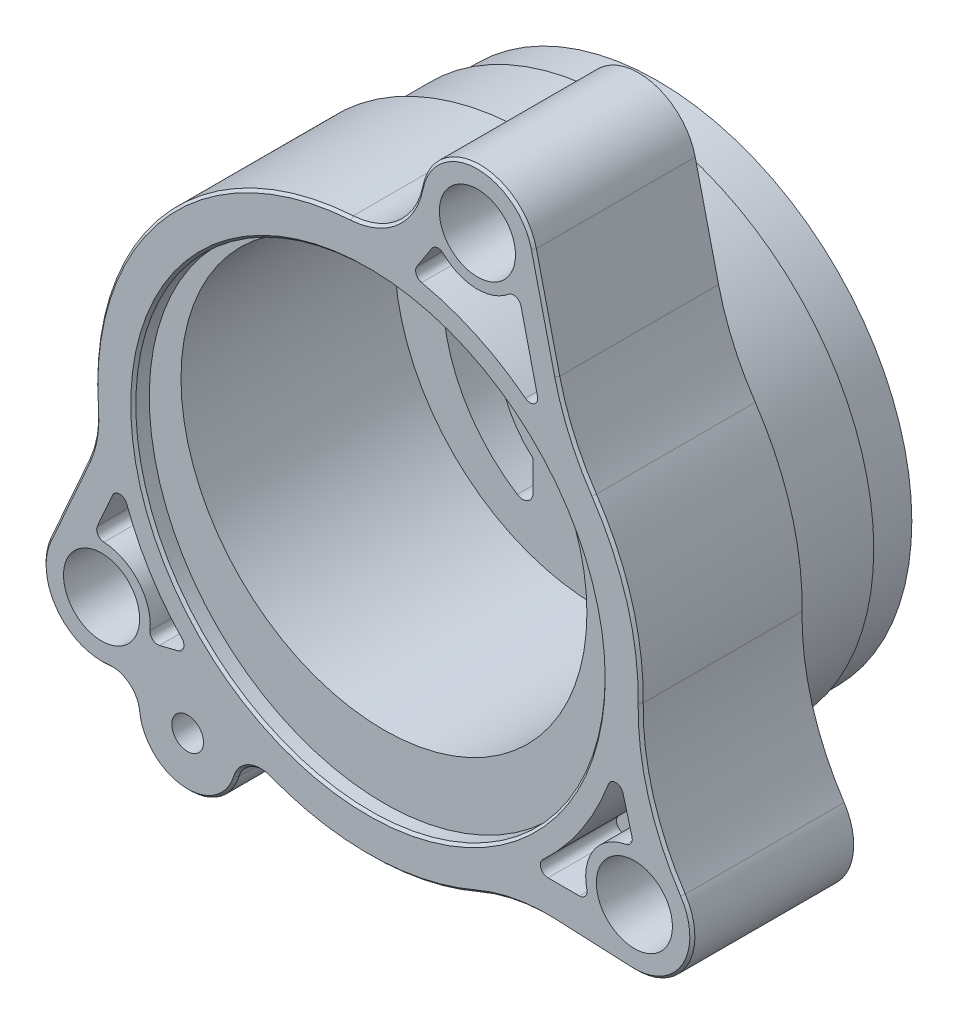
from build123d import *

# Parameters (mm, degrees)
BASE_DEPTH            = 16.1544
SKETCH2_R             = 25.9715
BOSS_I_DEPTH          = 8.509
SKETCH3_R             = 25.4635
BOSS_II_DEPTH         = 4.318
SKETCH4_R             = 23.495
TOP_SEAL_CUT_DEPTH    = 1.6002
SKETCH5_R             = 20.32
ECCENTRIC_DEPTH       = 21.3868
SKETCH6_R             = 23.9395
BOTTOM_SEAL_CUT_DEPTH = 1.27
INTAKE_PORT_DEPTH     = 29.9814
EXHAUST_PORT_DEPTH    = 29.9814
POCKET_1_DEPTH        = 2.794
POCKET_2_DEPTH        = 2.794
POCKET_3_DEPTH        = 2.794
SKETCH12_R            = 6.1595
SHAFT_BOSS_DEPTH      = 2.794
SKETCH13_R            = 4.8895
SHAFT_RACE_DEPTH      = 31.5054
FILLET1_R             = 0.127
SKETCH14_R            = 3.81
MOUNTING_HOLES_DEPTH  = 31.5054001
MOUNTING_HOLES_TAPER  = 3
CHAMFER1_SIZE         = 0.254
SKETCH15_R            = 1.5875
SCREW_HOLE_DEPTH      = 31.5054001
SKETCH16_R            = 3.302
SCREW_C_BORE_DEPTH    = 13.462
CASTING_CUTS_DEPTH    = 7.62


with BuildPart() as part:
    # Sketch1 → Base (new body)
    with BuildSketch(Plane.XY):
        with BuildLine():
            Line((16.604256141, 33.560634381), (18.943472312, 23.673588932))
            ThreePointArc((18.943472312, 23.673588932), (20.401103388, 19.31706117), (22.619598737, 15.294338102))
            ThreePointArc((22.619598737, 15.294338102), (26.177171365, 7.766513011), (27.300719551, -0.483463539))
            ThreePointArc((27.300719551, -0.483463539), (28.309281475, -8.033336288), (31.510952034, -14.944709618))
            ThreePointArc((31.510952034, -14.944709618), (31.716980405, -21.01221602), (26.400801283, -23.943993837))
            Line((26.400801283, -23.943993837), (18.789002246, -23.590560073))
            ThreePointArc((18.789002246, -23.590560073), (14.751162948, -23.864172006), (10.879801534, -25.043820467))
            ThreePointArc((10.879801534, -25.043820467), (0.563483635, -27.299185175), (-9.837113925, -25.471439194))
            ThreePointArc((-9.837113925, -25.471439194), (-11.86980955, -25.559968532), (-13.185383912, -27.112048762))
            ThreePointArc((-13.185383912, -27.112048762), (-18.53278197, -30.71157068), (-23.105685308, -26.168468316))
            ThreePointArc((-23.105685308, -26.168468316), (-24.05058816, -24.438373185), (-25.948431352, -23.905211124))
            ThreePointArc((-25.948431352, -23.905211124), (-31.329446418, -21.606804698), (-31.974558392, -15.791151184))
            Line((-31.974558392, -15.791151184), (-28.068905544, -6.994505511))
            ThreePointArc((-28.068905544, -6.994505511), (-27.342210837, -4.596155707), (-27.224673499, -2.092887453))
            ThreePointArc((-27.224673499, -2.092887453), (-20.610396453, 17.910180989), (-1.725707135, 27.250412105))
            ThreePointArc((-1.725707135, 27.250412105), (2.807988712, 29.118342831), (5.264931729, 33.361807717))
            ThreePointArc((5.264931729, 33.361807717), (10.854529977, 38.027365143), (16.604256141, 33.560634381))
        make_face()
    extrude(amount=BASE_DEPTH)

    # Sketch2 → Boss I (add)
    with BuildSketch(Plane(origin=(0, 0, 0), x_dir=(-1, 0, 0), z_dir=(0, 0, -1))):
        Circle(SKETCH2_R)
    extrude(amount=BOSS_I_DEPTH)

    # Sketch3 → Boss II (add)
    with BuildSketch(Plane(origin=(0, 0, -8.509), x_dir=(-1, 0, 0), z_dir=(0, 0, -1))):
        Circle(SKETCH3_R)
    extrude(amount=BOSS_II_DEPTH)

    # Sketch4 → Top Seal Cut (cut)
    with BuildSketch(Plane.XY.offset(16.1544)):
        Circle(SKETCH4_R)
    extrude(amount=-TOP_SEAL_CUT_DEPTH, mode=Mode.SUBTRACT)

    # Sketch5 → Eccentric (cut)
    with BuildSketch(Plane.XY.offset(14.5542)):
        with Locations((0, 3.175)):
            Circle(SKETCH5_R)
    extrude(amount=-ECCENTRIC_DEPTH, mode=Mode.SUBTRACT)

    # Sketch6 → Bottom Seal Cut (cut)
    with BuildSketch(Plane(origin=(0, 0, -12.827), x_dir=(-1, 0, 0), z_dir=(0, 0, -1))):
        Circle(SKETCH6_R)
        with BuildLine():
            Line((-1.27, 19.840574746), (-1.27, 10.506515883))
            ThreePointArc((-1.27, 10.506515883), (-1.730215265, 9.04840222), (-2.944090909, 8.118671364))
            ThreePointArc((-2.944090909, 8.118671364), (-8.636, 0), (-2.944090909, -8.118671364))
            ThreePointArc((-2.944090909, -8.118671364), (-1.730215265, -9.04840222), (-1.27, -10.506515883))
            Line((-1.27, -10.506515883), (-1.27, -19.840574746))
            ThreePointArc((-1.27, -19.840574746), (-1.70092691, -20.793914323), (-2.701269841, -21.100293777))
            ThreePointArc((-2.701269841, -21.100293777), (-21.2725, 0), (-2.701269841, 21.100293777))
            ThreePointArc((-2.701269841, 21.100293777), (-1.70092691, 20.793914323), (-1.27, 19.840574746))
        make_face(mode=Mode.SUBTRACT)
        with BuildLine():
            Line((1.27, 19.840574746), (1.27, 10.506515883))
            ThreePointArc((1.27, 10.506515883), (1.730215265, 9.04840222), (2.944090909, 8.118671364))
            ThreePointArc((2.944090909, 8.118671364), (8.636, 0), (2.944090909, -8.118671364))
            ThreePointArc((2.944090909, -8.118671364), (1.730215265, -9.04840222), (1.27, -10.506515883))
            Line((1.27, -10.506515883), (1.27, -19.840574746))
            ThreePointArc((1.27, -19.840574746), (1.70092691, -20.793914323), (2.701269841, -21.100293777))
            ThreePointArc((2.701269841, -21.100293777), (21.2725, 0), (2.701269841, 21.100293777))
            ThreePointArc((2.701269841, 21.100293777), (1.70092691, 20.793914323), (1.27, 19.840574746))
        make_face(mode=Mode.SUBTRACT)
    extrude(amount=-BOTTOM_SEAL_CUT_DEPTH, mode=Mode.SUBTRACT)

    # Sketch7 → Intake Port (cut, through all)
    with BuildSketch(Plane(origin=(0, 0, -12.827), x_dir=(-1, 0, 0), z_dir=(0, 0, -1))):
        with BuildLine():
            Line((6.477, 7.495152233), (6.477, 14.394282993))
            ThreePointArc((6.477, 14.394282993), (7.154191662, 15.517438492), (8.463579959, 15.44281204))
            ThreePointArc((8.463579959, 15.44281204), (15.47894101, 1.89335056), (8.039508682, -11.42798735))
            ThreePointArc((8.039508682, -11.42798735), (7.004633755, -11.462420973), (6.477, -10.571492014))
            Line((6.477, -10.571492014), (6.477, -7.495152233))
            ThreePointArc((6.477, -7.495152233), (9.906, 0), (6.477, 7.495152233))
        make_face()
    extrude(amount=-INTAKE_PORT_DEPTH, mode=Mode.SUBTRACT)

    # Sketch8 → Exhaust Port (cut, through all)
    with BuildSketch(Plane(origin=(0, 0, -12.827), x_dir=(-1, 0, 0), z_dir=(0, 0, -1))):
        with BuildLine():
            Line((-9.525, 2.720884231), (-9.525, 9.070884231))
            ThreePointArc((-9.525, 9.070884231), (-11.257750781, 11.254497488), (-13.777980834, 10.063265939))
            ThreePointArc((-13.777980834, 10.063265939), (-14.371790492, -2.970554124), (-5.192506336, -12.242760859))
            ThreePointArc((-5.192506336, -12.242760859), (-4.010815754, -12.112747852), (-3.4544, -11.062177758))
            Line((-3.4544, -11.062177758), (-3.4544, -9.284177758))
            ThreePointArc((-3.4544, -9.284177758), (-8.84005568, -4.47015118), (-9.525, 2.720884231))
        make_face()
    extrude(amount=-EXHAUST_PORT_DEPTH, mode=Mode.SUBTRACT)

    # Sketch9 → Pocket 1 (cut)
    with BuildSketch(Plane(origin=(0, 0, -12.827), x_dir=(-1, 0, 0), z_dir=(0, 0, -1))):
        with BuildLine():
            Line((3.1496, -11.299886076), (3.1496, -18.514300269))
            ThreePointArc((3.1496, -18.514300269), (3.431694665, -19.106191196), (4.069114094, -19.259842561))
            ThreePointArc((4.069114094, -19.259842561), (12.540368113, -15.173608423), (18.148870298, -7.623498667))
            ThreePointArc((18.148870298, -7.623498667), (18.080964228, -6.906628151), (17.446333383, -6.566395493))
            Line((17.446333383, -6.566395493), (15.786183774, -6.566395493))
            ThreePointArc((15.786183774, -6.566395493), (15.405217137, -6.668464873), (15.126310944, -6.947328768))
            ThreePointArc((15.126310944, -6.947328768), (12.518403705, -10.424638298), (9.159851479, -13.183802789))
            ThreePointArc((9.159851479, -13.183802789), (6.275256454, -13.420994092), (4.453004865, -11.172317298))
            ThreePointArc((4.453004865, -11.172317298), (3.74345607, -10.645069683), (3.1496, -11.299886076))
        make_face()
    extrude(amount=-POCKET_1_DEPTH, mode=Mode.SUBTRACT)

    # Sketch10 → Pocket 2 (cut)
    with BuildSketch(Plane(origin=(0, 0, -12.827), x_dir=(-1, 0, 0), z_dir=(0, 0, -1))):
        with BuildLine():
            Line((-3.1496, -16.375080355), (-3.1496, -18.514300269))
            ThreePointArc((-3.1496, -18.514300269), (-3.431694665, -19.106191196), (-4.069114094, -19.259842561))
            ThreePointArc((-4.069114094, -19.259842561), (-13.894614146, -13.944135783), (-19.245243831, -4.137609804))
            ThreePointArc((-19.245243831, -4.137609804), (-19.093010331, -3.498592586), (-18.50026665, -3.215444263))
            Line((-18.50026665, -3.215444263), (-17.792292075, -3.215444263))
            ThreePointArc((-17.792292075, -3.215444263), (-17.356402624, -3.352428754), (-17.077232582, -3.714130913))
            ThreePointArc((-17.077232582, -3.714130913), (-11.890715347, -11.339293456), (-3.730413278, -15.634934848))
            ThreePointArc((-3.730413278, -15.634934848), (-3.312138457, -15.904665794), (-3.1496, -16.375080355))
        make_face()
    extrude(amount=-POCKET_2_DEPTH, mode=Mode.SUBTRACT)

    # Sketch11 → Pocket 3 (cut)
    with BuildSketch(Plane(origin=(0, 0, -12.827), x_dir=(-1, 0, 0), z_dir=(0, 0, -1))):
        with BuildLine():
            Line((-3.1496, 17.890779888), (-3.1496, 9.712901548))
            ThreePointArc((-3.1496, 9.712901548), (-4.45441743, 9.187959621), (-5.674722083, 8.488696361))
            ThreePointArc((-5.674722083, 8.488696361), (-6.4542935, 8.448498977), (-6.860177613, 9.115286432))
            ThreePointArc((-6.860177613, 9.115286432), (-8.069580004, 12.29712311), (-11.058112281, 13.926667101))
            ThreePointArc((-11.058112281, 13.926667101), (-11.686704891, 14.493715403), (-11.403528613, 15.291514652))
            ThreePointArc((-11.403528613, 15.291514652), (-7.917467255, 17.354670767), (-4.074357282, 18.63519514))
            ThreePointArc((-4.074357282, 18.63519514), (-3.433780499, 18.484355936), (-3.1496, 17.890779888))
        make_face()
    extrude(amount=-POCKET_3_DEPTH, mode=Mode.SUBTRACT)

    # Sketch12 → Shaft Boss (add)
    with BuildSketch(Plane(origin=(0, 0, -11.557), x_dir=(-1, 0, 0), z_dir=(0, 0, -1))):
        Circle(SKETCH12_R)
    extrude(amount=SHAFT_BOSS_DEPTH)

    # Sketch13 → Shaft Race (cut, through all)
    with BuildSketch(Plane(origin=(0, 0, -14.351), x_dir=(-1, 0, 0), z_dir=(0, 0, -1))):
        Circle(SKETCH13_R)
    extrude(amount=-SHAFT_RACE_DEPTH, mode=Mode.SUBTRACT)

    # Fillet1
    fillet1_edges = [part.edges().sort_by_distance(p)[0] for p in [
        (-9.906, 0, -12.827),
        (-6.477, 10.944717613, -12.827),
        (-15.47894101, 1.89335056, -12.827),
        (-7.004633755, -11.462420973, -12.827),
        (-6.477, -9.033322123, -12.827),
        (-7.154191662, 15.517438492, -12.827),
        (8.84005568, -4.47015118, -12.827),
        (3.4544, -10.173177758, -12.827),
        (4.010815754, -12.112747852, -12.827),
        (9.525, 5.895884231, -12.827),
        (11.257750781, 11.254497488, -12.827),
        (14.371790492, -2.970554124, -12.827),
        (-3.74345607, -10.645069683, -12.827),
        (-6.275256454, -13.420994092, -12.827),
        (-12.518403705, -10.424638298, -12.827),
        (-16.616258578, -6.566395493, -12.827),
        (-3.431694665, -19.106191196, -12.827),
        (-3.1496, -14.907093172, -12.827),
        (-12.540368113, -15.173608423, -12.827),
        (-18.080964228, -6.906628151, -12.827),
        (-15.405217137, -6.668464873, -12.827),
        (3.431694665, -19.106191196, -12.827),
        (18.146279363, -3.215444263, -12.827),
        (11.890715347, -11.339293456, -12.827),
        (3.1496, -17.444690312, -12.827),
        (3.312138457, -15.904665794, -12.827),
        (17.356402624, -3.352428754, -12.827),
        (19.093010331, -3.498592586, -12.827),
        (13.894614146, -13.944135783, -12.827),
        (6.4542935, 8.448498977, -12.827),
        (7.917467255, 17.354670767, -12.827),
        (3.1496, 13.801840718, -12.827),
        (4.45441743, 9.187959621, -12.827),
        (3.433780499, 18.484355936, -12.827),
        (11.686704891, 14.493715403, -12.827),
        (8.069580004, 12.29712311, -12.827),
        (6.1595, 0, -14.351),
        (4.8895, 0, -14.351),
        (-1.70092691, -20.793914323, -12.827),
        (-8.636, 0, -12.827),
        (-1.730215265, 9.04840222, -12.827),
        (1.27, 15.173545314, -12.827),
        (1.730215265, 9.04840222, -12.827),
        (8.636, 0, -12.827),
        (1.27, -15.173545314, -12.827),
        (1.70092691, 20.793914323, -12.827),
        (1.730215265, -9.04840222, -12.827),
        (1.70092691, -20.793914323, -12.827),
        (21.2725, 0, -12.827),
        (-1.70092691, 20.793914323, -12.827),
        (-21.2725, 0, -12.827),
        (-1.27, -15.173545314, -12.827),
        (-1.730215265, -9.04840222, -12.827),
        (-1.27, 15.173545314, -12.827),
    ]]
    fillet(fillet1_edges, radius=FILLET1_R)

    # Sketch14 → Mounting Holes (cut, through all)
    with BuildSketch(Plane.XY.offset(16.1544)):
        with Locations((10.956281429, 32.224357143)):
            Circle(SKETCH14_R)
        with Locations((-26.67, -18.146340237)):
            Circle(SKETCH14_R)
        with Locations((26.67, -18.146340237)):
            Circle(SKETCH14_R)
    extrude(amount=-MOUNTING_HOLES_DEPTH, taper=MOUNTING_HOLES_TAPER, mode=Mode.SUBTRACT)

    # Chamfer1
    chamfer1_edges = [part.edges().sort_by_distance(p)[0] for p in [
        (-20.610396453, 17.910180989, 16.1544),
        (-27.342210837, -4.596155707, 16.1544),
        (-30.021731968, -11.392828348, 16.1544),
        (-31.329446418, -21.606804698, 16.1544),
        (-24.05058816, -24.438373185, 16.1544),
        (-18.53278197, -30.71157068, 16.1544),
        (-11.86980955, -25.559968532, 16.1544),
        (0.563483635, -27.299185175, 16.1544),
        (14.751162948, -23.864172006, 16.1544),
        (22.594901765, -23.767276955, 16.1544),
        (10.854529977, 38.027365143, 16.1544),
        (31.716980405, -21.01221602, 16.1544),
        (28.309281475, -8.033336288, 16.1544),
        (26.177171365, 7.766513011, 16.1544),
        (20.401103388, 19.31706117, 16.1544),
        (17.773864227, 28.617111656, 16.1544),
        (-23.495, 0, 16.1544),
        (2.807988712, 29.118342831, 16.1544),
    ]]
    chamfer(chamfer1_edges, length=CHAMFER1_SIZE)

    # Sketch15 → Screw Hole (cut, through all)
    with BuildSketch(Plane.XY.offset(16.1544)):
        with Locations((-18.051763155, -25.654395491)):
            Circle(SKETCH15_R)
    extrude(amount=-SCREW_HOLE_DEPTH, mode=Mode.SUBTRACT)

    # Sketch16 → Screw C-Bore (cut)
    with BuildSketch(Plane(origin=(0, 0, 0), x_dir=(-1, 0, 0), z_dir=(0, 0, -1))):
        with Locations((18.051763155, -25.654395491)):
            Circle(SKETCH16_R)
    extrude(amount=-SCREW_C_BORE_DEPTH, mode=Mode.SUBTRACT)

    # Sketch17 → Casting Cuts (cut)
    with BuildSketch(Plane.XY.offset(16.1544)):
        with BuildLine():
            Line((4.891893169, 26.29743204), (6.385468695, 28.59739914))
            ThreePointArc((6.385468695, 28.59739914), (6.939649811, 28.939648698), (7.555857116, 28.728603614))
            ThreePointArc((7.555857116, 28.728603614), (10.774651006, 27.350940617), (14.087062862, 28.485188003))
            ThreePointArc((14.087062862, 28.485188003), (14.816454705, 28.624091828), (15.31777587, 28.076384038))
            Line((15.31777587, 28.076384038), (16.972886727, 21.080811561))
            ThreePointArc((16.972886727, 21.080811561), (16.643494597, 20.264443139), (15.764044739, 20.303488284))
            ThreePointArc((15.764044739, 20.303488284), (10.840733231, 23.306978484), (5.371724448, 25.137249641))
            ThreePointArc((5.371724448, 25.137249641), (4.826812114, 25.591199507), (4.891893169, 26.29743204))
        make_face()
        with BuildLine():
            Line((-25.560610138, -8.76076781), (-27.089876063, -12.205111433))
            ThreePointArc((-27.089876063, -12.205111433), (-27.042284474, -12.913874541), (-26.430808766, -13.275409546))
            ThreePointArc((-26.430808766, -13.275409546), (-22.974606815, -14.964006589), (-21.8174918, -18.632490845))
            ThreePointArc((-21.8174918, -18.632490845), (-21.557491963, -19.285024689), (-20.874144429, -19.447617679))
            Line((-20.874144429, -19.447617679), (-18.994942854, -18.976923619))
            ThreePointArc((-18.994942854, -18.976923619), (-18.448306314, -18.450226063), (-18.627876055, -17.712678417))
            ThreePointArc((-18.627876055, -17.712678417), (-21.846511468, -13.544987254), (-24.148310213, -8.808851055))
            ThreePointArc((-24.148310213, -8.808851055), (-24.838241138, -8.30842425), (-25.560610138, -8.76076781))
        make_face()
        with BuildLine():
            Line((18.022095875, -20.144867758), (21.168448843, -20.144867758))
            ThreePointArc((21.168448843, -20.144867758), (21.763416454, -19.858953404), (21.911901702, -19.215769444))
            ThreePointArc((21.911901702, -19.215769444), (22.612816894, -15.440338855), (25.829115282, -13.342582215))
            ThreePointArc((25.829115282, -13.342582215), (26.340539413, -13.001184785), (26.433373569, -12.393328992))
            Line((26.433373569, -12.393328992), (25.531922284, -9.055317471))
            ThreePointArc((25.531922284, -9.055317471), (24.831858789, -8.492814765), (24.082371467, -8.987554036))
            ThreePointArc((24.082371467, -8.987554036), (21.36664267, -14.289972849), (17.503225552, -18.824819742))
            ThreePointArc((17.503225552, -18.824819742), (17.312914449, -19.66162519), (18.022095875, -20.144867758))
        make_face()
    extrude(amount=-CASTING_CUTS_DEPTH, mode=Mode.SUBTRACT)


solid = part.part
